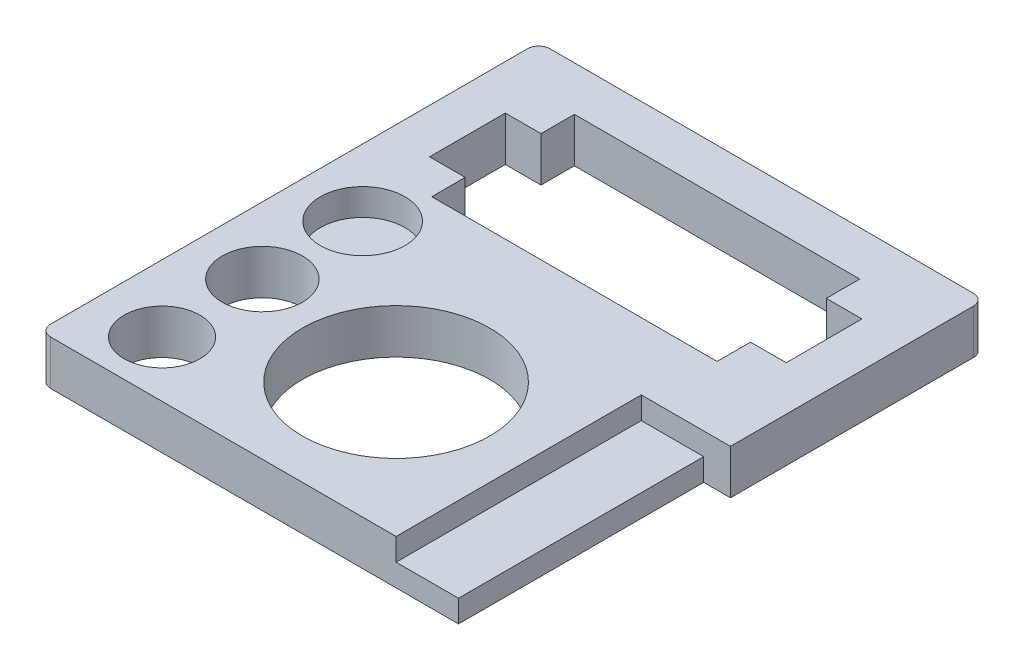
from build123d import *

# Parameters (mm, degrees)
ESQUISSE1_R             = 1.7
ESQUISSE1_R_2           = 1.8
ESQUISSE1_R_3           = 4.2
BOSS_EXTRU_1_DEPTH      = 2
ESQUISSE2_R             = 1.9
ENL_V_MAT_EXTRU_1_DEPTH = 1.2
ESQUISSE4_W             = 2.8
ESQUISSE4_H             = 11
BOSS_EXTRU_3_DEPTH      = 1
CONG_1_R                = 0.5


with BuildPart() as part:
    # Esquisse1 → Boss.-Extru.1 (new body)
    with BuildSketch(Plane(origin=(0, 0, 0), x_dir=(1, 0, 0), z_dir=(0, 1, 0))):
        Polygon((10, 16.4), (-10, 16.4), (-10, -6), (6, -6), (6, 5), (10, 5), align=None)
        with Locations((-7, -3.5)):
            Circle(ESQUISSE1_R, mode=Mode.SUBTRACT)
        with Locations((-7, 1)):
            Circle(ESQUISSE1_R_2, mode=Mode.SUBTRACT)
        Circle(ESQUISSE1_R_3, mode=Mode.SUBTRACT)
        Polygon((-6.4, 12.9), (-6.4, 14.4), (6.4, 14.4), (6.4, 12.9), (8, 12.9), (8, 9.5), (6.4, 9.5), (6.4, 8), (-6.4, 8), (-6.4, 9.5), (-8, 9.5), (-8, 12.9), align=None, mode=Mode.SUBTRACT)
    extrude(amount=BOSS_EXTRU_1_DEPTH)

    # Esquisse2 → Enlèv. mat.-Extru.1 (cut)
    with BuildSketch(Plane(origin=(0, 2, 0), x_dir=(1, 0, 0), z_dir=(0, 1, 0))):
        with Locations((-7, 5.5)):
            Circle(ESQUISSE2_R)
    extrude(amount=-ENL_V_MAT_EXTRU_1_DEPTH, mode=Mode.SUBTRACT)

    # Esquisse4 → Boss.-Extru.3 (add)
    with BuildSketch(Plane.XZ):
        with Locations((7.4, 0.5)):
            Rectangle(ESQUISSE4_W, ESQUISSE4_H)
    extrude(amount=-BOSS_EXTRU_3_DEPTH)

    # Congé1
    cong_1_edges = [part.edges().sort_by_distance(p)[0] for p in [
        (-10, 1, 6),
        (-10, 1, -16.4),
        (10, 1, -16.4),
    ]]
    fillet(cong_1_edges, radius=CONG_1_R)


solid = part.part
